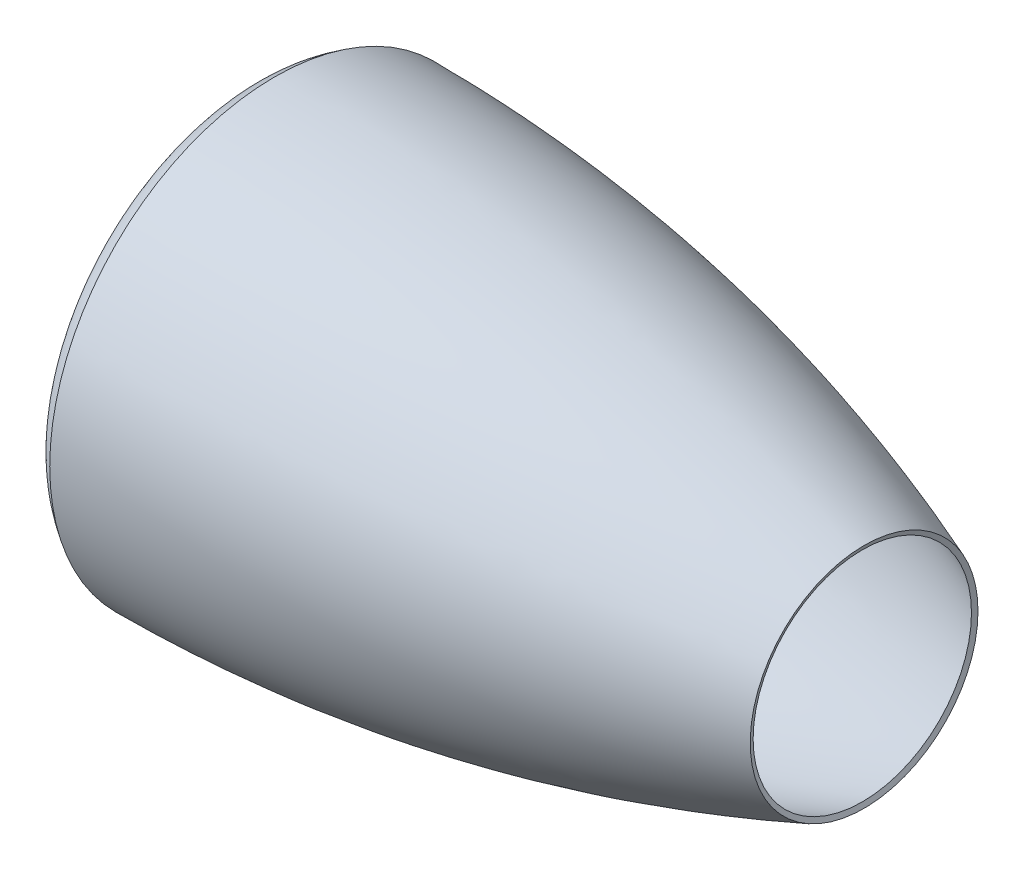
from build123d import *

# Parameters (mm, degrees)
THICKEN1_T1 = 5


with BuildPart() as body_1:
    # Surface-Revolve1: a surface, the sketch's curves turned about an axis
    with BuildLine(Plane.XY, mode=Mode.PRIVATE) as surface_revolve1_1_path:
        Line((65.979728767, 190), (40.979728767, 190))
        Line((40.979728767, 190), (25, 180))
        Line((25, 180), (0, 180))
        add(Edge.make_bspline(
            [(0, 180), (-35.422013569, 196.120389522), (0, 217.479514847)],
            knots=[0, 0, 0, 1, 1, 1], degree=2))
        add(Edge.make_bspline(
            [(0, 217.479514847), (298.188474244, 216.475161748), (580, 108)],
            knots=[0, 0, 0, 1, 1, 1], degree=2))
    surface_revolve1_1 = Shell.revolve(surface_revolve1_1_path.wire(), 360, Axis((0, 0, 0), (1, 0, 0)))
    add(Solid.thicken(surface_revolve1_1, THICKEN1_T1))


solid = body_1.part
